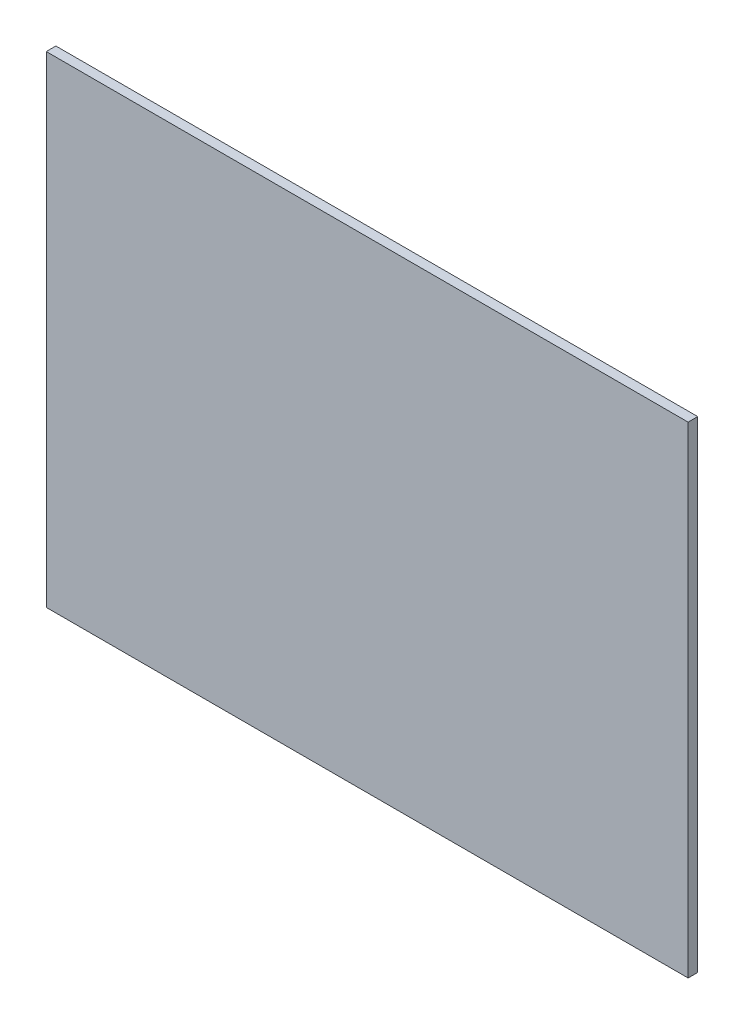
from build123d import *

# Parameters (mm, degrees)
SKETCH1_W           = 1219.2
SKETCH1_H           = 914.4
BOSS_EXTRUDE1_DEPTH = 18.25625


with BuildPart() as part:
    # Sketch1 → Boss-Extrude1 (new body)
    with BuildSketch(Plane.XY):
        Rectangle(SKETCH1_W, SKETCH1_H)
    extrude(amount=BOSS_EXTRUDE1_DEPTH)


solid = part.part
